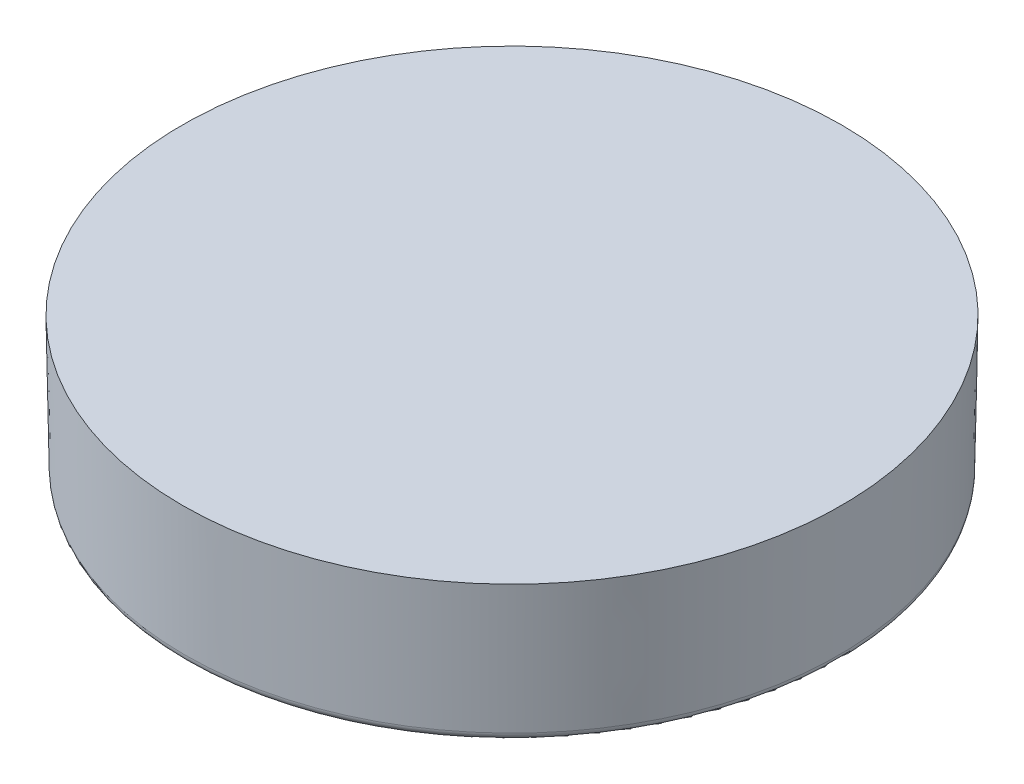
from build123d import *

# Parameters (mm, degrees)
SKETCH1_R           = 15.08125
BOSS_EXTRUDE1_DEPTH = 2.3114
BOSS_EXTRUDE1_DRAFT = -1
SKETCH7_R           = 15.08125
SKETCH7_R_2         = 13.30325
BOSS_EXTRUDE3_DEPTH = 6.35
BOSS_EXTRUDE3_DRAFT = -1
DRAFT1_ANGLE        = 10
FILLET2_R           = 0.381


with BuildPart() as part:
    # Sketch1 → Boss-Extrude1 (with draft: the straight prism first)
    with BuildSketch(Plane(origin=(0, 0, 0), x_dir=(1, 0, 0), z_dir=(0, 1, 0))):
        Circle(SKETCH1_R)
    extrude(amount=-BOSS_EXTRUDE1_DEPTH)
    # Boss-Extrude1: the draft: its side faces are tilted about the plane it starts from
    boss_extrude1_sides = [part.faces().sort_by_distance(p)[0] for p in [
        (-15.08125, -1.1557, 0),
    ]]
    draft(boss_extrude1_sides, Plane(origin=(0, 0, 0), x_dir=(1, 0, 0), z_dir=(0, 1, 0)), BOSS_EXTRUDE1_DRAFT)


with BuildPart() as boss_extrude3_tool:
    # Sketch7 → Boss-Extrude3 (with draft: the straight prism first)
    with BuildSketch(Plane(origin=(0, 0, 0), x_dir=(1, 0, 0), z_dir=(0, 1, 0))):
        Circle(SKETCH7_R)
        Circle(SKETCH7_R_2, mode=Mode.SUBTRACT)
    extrude(amount=-BOSS_EXTRUDE3_DEPTH)
    # Boss-Extrude3: the draft: its side faces are tilted about the plane it starts from
    boss_extrude3_sides = [boss_extrude3_tool.faces().sort_by_distance(p)[0] for p in [
        (-15.08125, -3.175, 0),
        (-13.30325, -3.175, 0),
    ]]
    draft(boss_extrude3_sides, Plane(origin=(0, 0, 0), x_dir=(1, 0, 0), z_dir=(0, 1, 0)), BOSS_EXTRUDE3_DRAFT)


with BuildPart() as part_1:
    add(part.part)

    # Boss-Extrude3: add boss_extrude3_tool
    add(boss_extrude3_tool.part)

    # Draft1
    draft1_faces = [part_1.faces().sort_by_distance(p)[0] for p in [
        (-13.37884265, -4.3307, 0),
    ]]
    draft(draft1_faces, Plane(origin=(0, -2.3114, 0), x_dir=(0, 0, -1), z_dir=(0, -1, 0)), DRAFT1_ANGLE)

    # Fillet2
    fillet2_edges = [part_1.edges().sort_by_distance(p)[0] for p in [
        (-14.970410338, -6.35, 0),
        (-14.055709781, -6.35, 0),
    ]]
    fillet(fillet2_edges, radius=FILLET2_R)


solid = part_1.part
